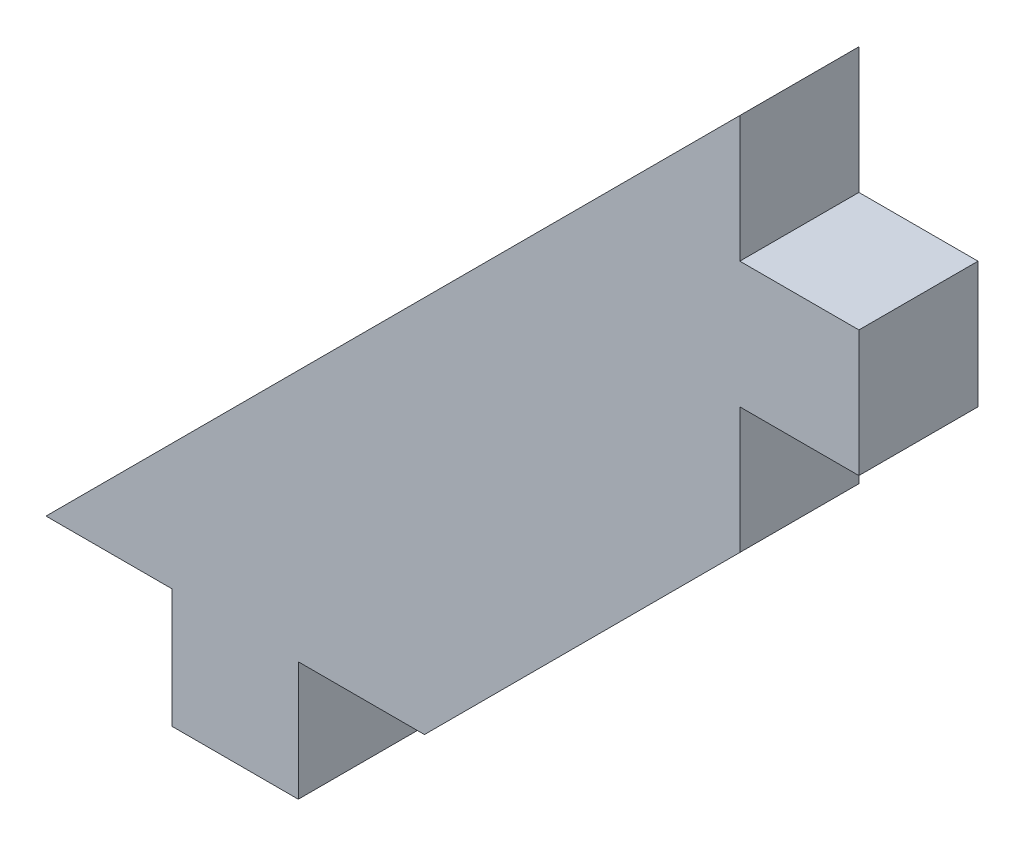
from build123d import *

# Parameters (mm, degrees)
BOSS_EXTRUDE1_DEPTH = 5.9944


with BuildPart() as part:
    # Sketch1 → Boss-Extrude1 (new body)
    with BuildSketch(Plane.XY):
        Polygon((-6.35, 5.9944), (0, 5.9944), (0, 0), (6.35, 0), (6.35, 5.9944), (12.7, 5.9944), (28.575, 21.8694), (28.575, 28.2194), (34.5694, 28.2194), (34.5694, 34.5694), (28.575, 34.5694), (28.575, 40.9194), align=None)
    extrude(amount=BOSS_EXTRUDE1_DEPTH)


solid = part.part
